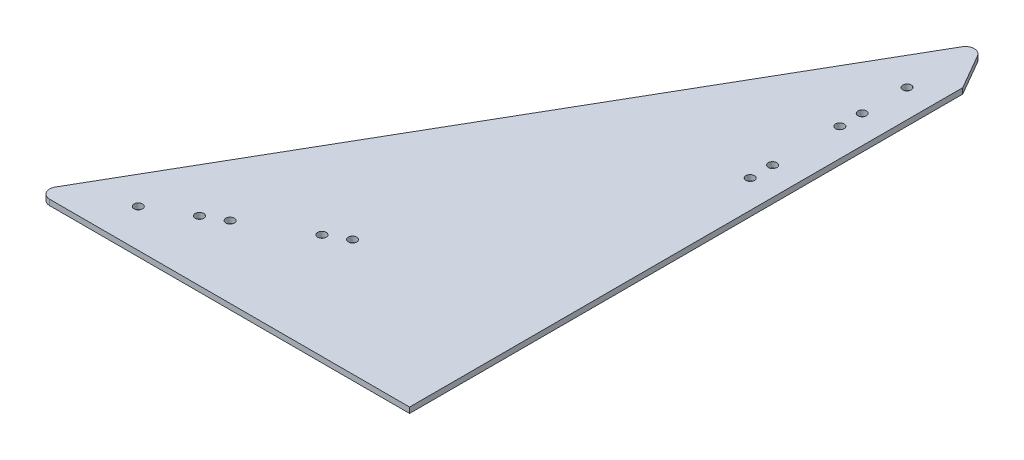
from build123d import *

# Parameters (mm, degrees)
BOSS_EXTRUDE1_DEPTH = 3.175
FILLET1_R           = 5.08
SKETCH2_R           = 2.413
CUT_EXTRUDE1_DEPTH  = 3.175
SKETCH3_R           = 2.413
CUT_EXTRUDE2_DEPTH  = 3.175


with BuildPart() as part:
    # Sketch1 → Boss-Extrude1 (new body)
    with BuildSketch(Plane(origin=(0, 0, 0), x_dir=(1, 0, 0), z_dir=(0, 1, 0))):
        Polygon((0, 0), (393.7, 0), (196.85, 340.95420147), align=None)
    extrude(amount=BOSS_EXTRUDE1_DEPTH)

    # Fillet1
    fillet1_edges = [part.edges().sort_by_distance(p)[0] for p in [
        (196.85, 1.5875, -340.95420147),
        (393.7, 1.5875, 0),
        (0, 1.5875, 0),
    ]]
    fillet(fillet1_edges, radius=FILLET1_R)

    # Sketch2 → Cut-Extrude1 (cut)
    with BuildSketch(Plane(origin=(0, 3.175, 0), x_dir=(1, 0, 0), z_dir=(0, 1, 0))):
        with Locations((37.394976935, 21.59)):
            Circle(SKETCH2_R)
        with Locations((59.392022192, 34.29)):
            Circle(SKETCH2_R)
        with Locations((70.39054482, 40.64)):
            Circle(SKETCH2_R)
        with Locations((114.384635332, 66.04)):
            Circle(SKETCH2_R)
        with Locations((103.386112704, 59.69)):
            Circle(SKETCH2_R)
        with Locations((196.85, 297.77420147)):
            Circle(SKETCH2_R)
        with Locations((196.85, 272.37420147)):
            Circle(SKETCH2_R)
        with Locations((196.85, 259.67420147)):
            Circle(SKETCH2_R)
        with Locations((196.85, 221.57420147)):
            Circle(SKETCH2_R)
        with Locations((196.85, 208.87420147)):
            Circle(SKETCH2_R)
        with Locations((279.315364668, 66.04)):
            Circle(SKETCH2_R)
        with Locations((290.313887296, 59.69)):
            Circle(SKETCH2_R)
        with Locations((323.30945518, 40.64)):
            Circle(SKETCH2_R)
        with Locations((334.307977808, 34.29)):
            Circle(SKETCH2_R)
        with Locations((356.305023065, 21.59)):
            Circle(SKETCH2_R)
    extrude(amount=-CUT_EXTRUDE1_DEPTH, mode=Mode.SUBTRACT)

    # Sketch3 → Cut-Extrude2 (cut)
    with BuildSketch(Plane(origin=(0, 3.175, 0), x_dir=(1, 0, 0), z_dir=(0, 1, 0))):
        with BuildLine():
            Line((389.300590949, 7.62), (212.725, 313.4578949))
            Line((212.725, 313.4578949), (212.725, 0))
            Line((212.725, 0), (384.901181898, 0))
            ThreePointArc((384.901181898, 0), (389.300590949, 2.54), (389.300590949, 7.62))
        make_face()
        with Locations((290.313887296, 59.69)):
            Circle(SKETCH3_R, mode=Mode.SUBTRACT)
        with Locations((279.315364668, 66.04)):
            Circle(SKETCH3_R, mode=Mode.SUBTRACT)
        with Locations((323.30945518, 40.64)):
            Circle(SKETCH3_R, mode=Mode.SUBTRACT)
        with Locations((334.307977808, 34.29)):
            Circle(SKETCH3_R, mode=Mode.SUBTRACT)
        with Locations((356.305023065, 21.59)):
            Circle(SKETCH3_R, mode=Mode.SUBTRACT)
    extrude(amount=-CUT_EXTRUDE2_DEPTH, mode=Mode.SUBTRACT)


solid = part.part
